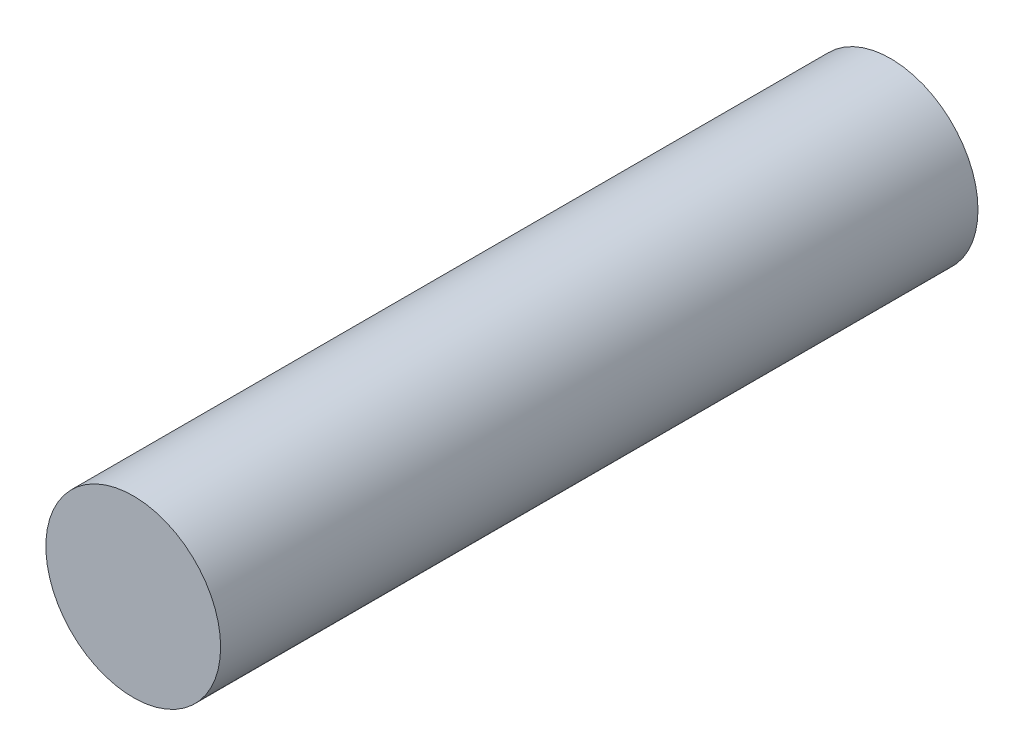
from build123d import *

# Parameters (mm, degrees)
SKETCH1_R           = 3
BOSS_EXTRUDE1_DEPTH = 26


with BuildPart() as part:
    # Sketch1 → Boss-Extrude1 (new body)
    with BuildSketch(Plane.XY):
        Circle(SKETCH1_R)
    extrude(amount=BOSS_EXTRUDE1_DEPTH)


solid = part.part
